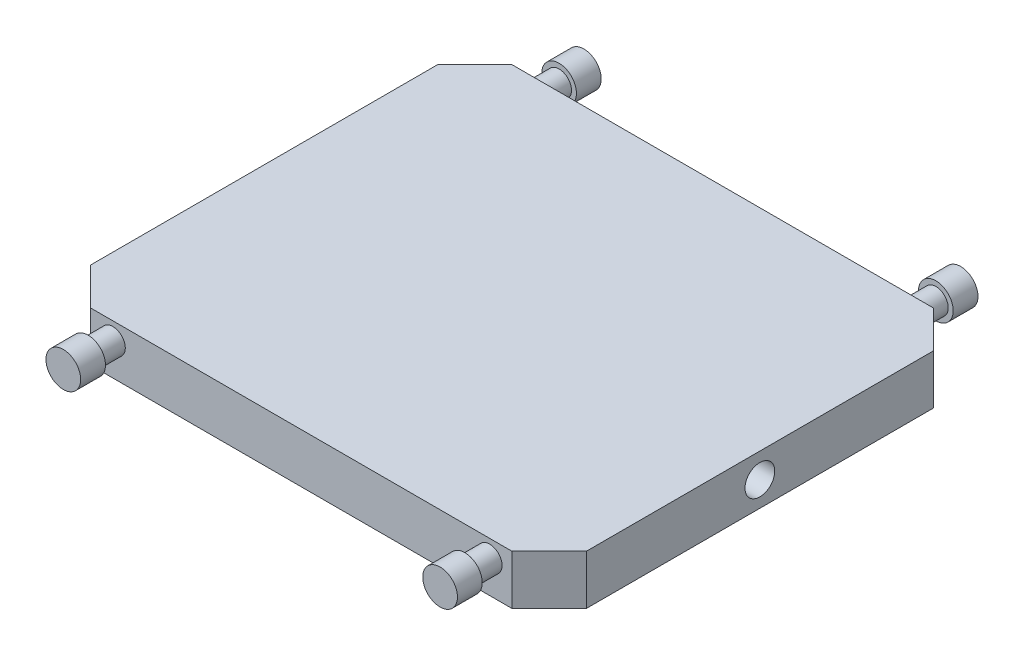
from build123d import *

# Parameters (mm, degrees)
BOSS_EXTRUDE1_DEPTH = 40
SKETCH2_R           = 12
CUT_EXTRUDE1_DEPTH  = 401
SKETCH3_R           = 10
BOSS_EXTRUDE2_DEPTH = 20
SKETCH4_R           = 14
BOSS_EXTRUDE3_DEPTH = 20


with BuildPart() as part:
    # Sketch1 → Boss-Extrude1 (new body)
    with BuildSketch(Plane(origin=(0, 0, 0), x_dir=(1, 0, 0), z_dir=(0, 1, 0))):
        Polygon((0, 310), (30, 340), (370, 340), (400, 310), (400, 30), (370, 0), (30, 0), (0, 30), align=None)
    extrude(amount=BOSS_EXTRUDE1_DEPTH)

    # Sketch2 → Cut-Extrude1 (cut, through all)
    with BuildSketch(Plane.ZY):
        with Locations((-170, 20)):
            Circle(SKETCH2_R)
    extrude(amount=-CUT_EXTRUDE1_DEPTH, mode=Mode.SUBTRACT)

    # Sketch3 → Boss-Extrude2 (add)
    with BuildSketch(Plane.XY):
        with Locations((48, 26)):
            Circle(SKETCH3_R)
        with Locations((352, 26)):
            Circle(SKETCH3_R)
    boss_extrude2 = extrude(amount=BOSS_EXTRUDE2_DEPTH)

    # Sketch4 → Boss-Extrude3 (add)
    with BuildSketch(Plane.XY.offset(20)):
        with Locations((48, 26)):
            Circle(SKETCH4_R)
        with Locations((352, 26)):
            Circle(SKETCH4_R)
    boss_extrude3 = extrude(amount=BOSS_EXTRUDE3_DEPTH)

    # Mirror1: Boss-Extrude2, Boss-Extrude3 across plane
    add(boss_extrude2.mirror(Plane.XY.offset(-170)))
    add(boss_extrude3.mirror(Plane.XY.offset(-170)))


solid = part.part
